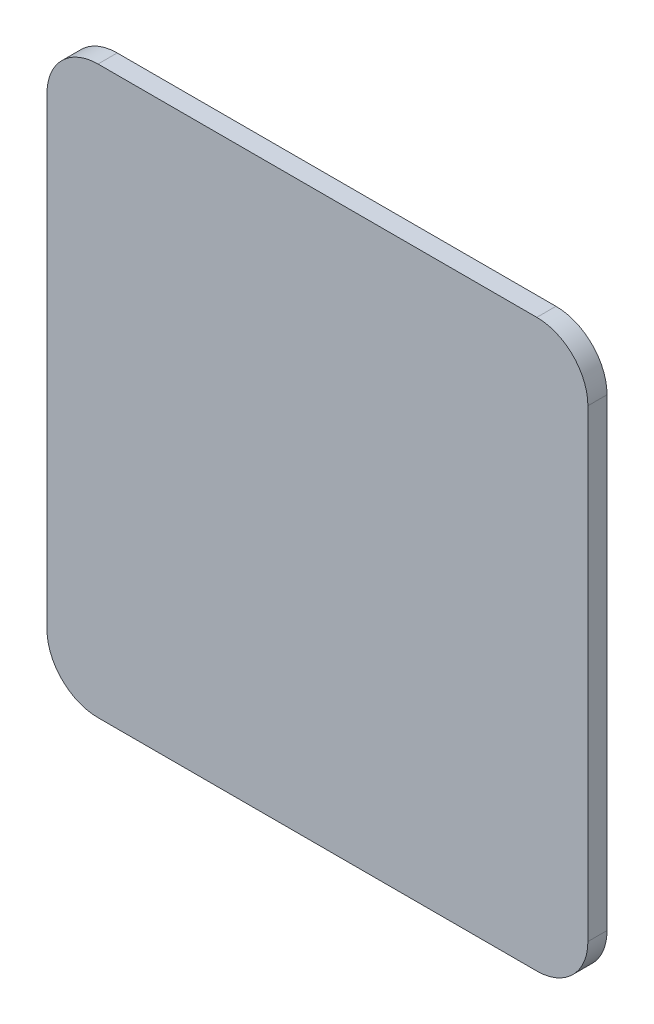
from build123d import *

# Parameters (mm, degrees)
BOSS_EXTRUDE1_DEPTH = 6


with BuildPart() as part:
    # Sketch1 → Boss-Extrude1 (new body)
    with BuildSketch(Plane.XY):
        with BuildLine():
            Line((-26, 10), (-163.5, 10))
            ThreePointArc((-163.5, 10), (-174.813708499, 14.686291501), (-179.5, 26))
            Line((-179.5, 26), (-179.5, 171.4))
            ThreePointArc((-179.5, 171.4), (-174.813708499, 182.713708499), (-163.5, 187.4))
            Line((-163.5, 187.4), (-26, 187.4))
            ThreePointArc((-26, 187.4), (-14.686291501, 182.713708499), (-10, 171.4))
            Line((-10, 171.4), (-10, 26))
            ThreePointArc((-10, 26), (-14.686291501, 14.686291501), (-26, 10))
        make_face()
    extrude(amount=BOSS_EXTRUDE1_DEPTH)


solid = part.part
